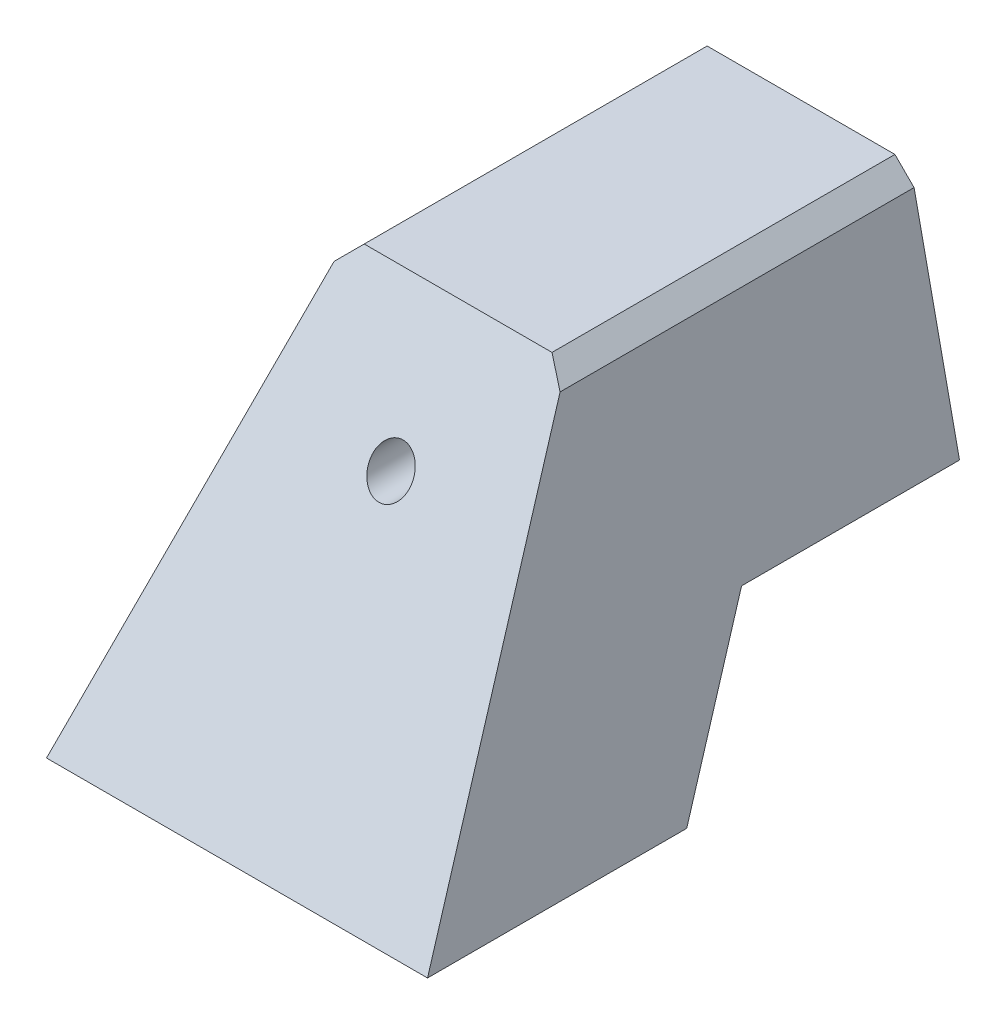
from build123d import *

# Parameters (mm, degrees)
SKETCH1_W               = 20.5
SKETCH1_H               = 20.5
BOSS_EXTRUDE1_DEPTH     = 75
SKETCH2_W               = 20.5
SKETCH2_H               = 20.5
SKETCH2_R               = 2.75
BOSS_EXTRUDE2_DEPTH     = 35
CUT_EXTRUDE1_DEPTH      = 26
CUT_EXTRUDE1_DEPTH_BACK = 26


with BuildPart() as part:
    # Sketch1 → Boss-Extrude1 (new body)
    with BuildSketch(Plane.XY):
        Polygon((-25, -35), (-14.832007533, 12.739060279), (-12.321067812, 15.25), (12.321067812, 15.25), (14.832007533, 12.739060279), (25, -35), align=None)
        Rectangle(SKETCH1_W, SKETCH1_H, mode=Mode.SUBTRACT)
    extrude(amount=BOSS_EXTRUDE1_DEPTH)

    # Sketch2 → Boss-Extrude2 (add)
    with BuildSketch(Plane.XY.offset(75)):
        Rectangle(SKETCH2_W, SKETCH2_H)
        Circle(SKETCH2_R, mode=Mode.SUBTRACT)
    extrude(amount=-BOSS_EXTRUDE2_DEPTH)

    # Sketch3 → Cut-Extrude1 (cut, two sides)
    with BuildSketch(Plane(origin=(0, 0, 0), x_dir=(0, 0, -1), z_dir=(1, 0, 0))) as cut_extrude1_sk:
        Polygon((0, -15.25), (-28.597332184, -15.25), (-40, -35), (0, -35), align=None)
        Polygon((-45, 15.25), (-75, -36.711524227), (-75, 15.25), align=None)
    extrude(amount=CUT_EXTRUDE1_DEPTH, mode=Mode.SUBTRACT)
    extrude(cut_extrude1_sk.sketch, amount=-CUT_EXTRUDE1_DEPTH_BACK, mode=Mode.SUBTRACT)


solid = part.part
